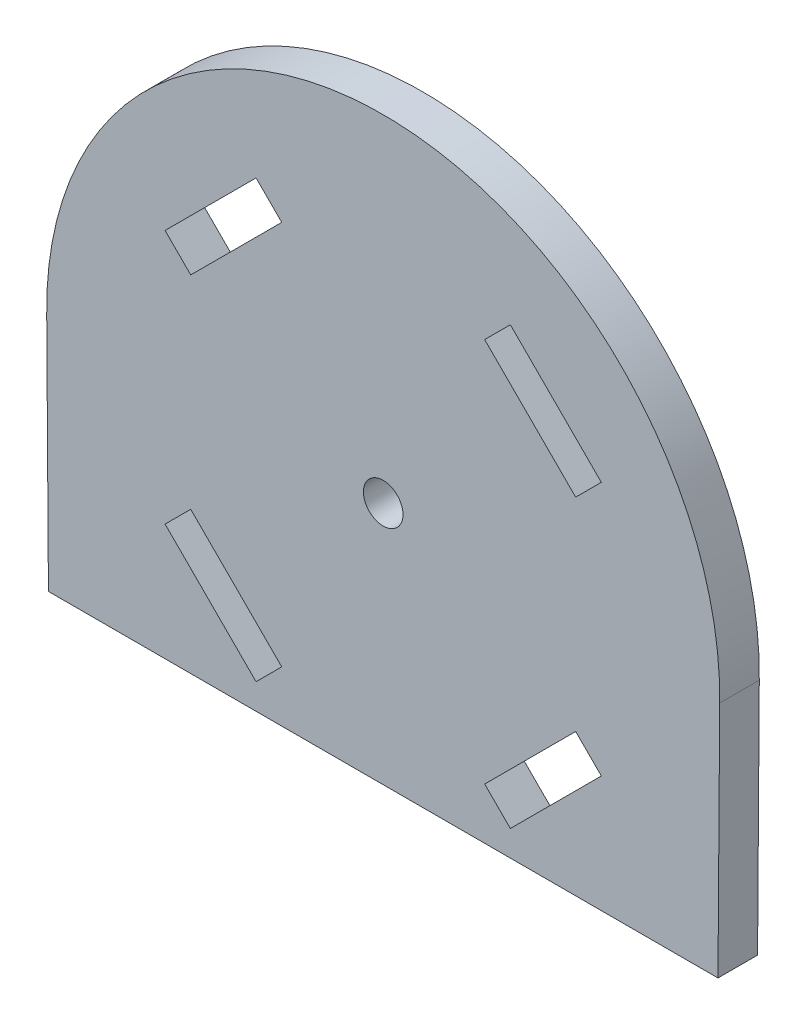
from build123d import *

# Parameters (mm, degrees)
MODEL_R             = 3
BOSS_EXTRUDE1_DEPTH = 6


with BuildPart() as part:
    # Model → Boss-Extrude1 (new body)
    with BuildSketch(Plane.XY):
        with BuildLine():
            Line((122.81162835, 8.788979227), (21.34180525, 8.788979227))
            Line((21.34180525, 8.788979227), (21.081967495, 45.003500256))
            ThreePointArc((21.081967495, 45.003500256), (72.0767168, 96.735308544), (123.071466105, 45.003500256))
            Line((123.071466105, 45.003500256), (122.81162835, 8.788979227))
        make_face()
        with Locations((72.0767168, 45.735308544)):
            Circle(MODEL_R, mode=Mode.SUBTRACT)
        Polygon((49.802853193, 68.009172151), (56.697144309, 74.903463268), (52.808057013, 78.792550564), (39.01947478, 65.003968331), (42.908562076, 61.114881035), align=None, mode=Mode.SUBTRACT)
        Polygon((49.802853193, 23.461444937), (56.697144309, 16.56715382), (52.808057013, 12.678066524), (39.01947478, 26.466648757), (42.908562076, 30.355736053), align=None, mode=Mode.SUBTRACT)
        Polygon((94.350580407, 68.009172151), (101.244871524, 61.114881035), (105.13395882, 65.003968331), (91.345376587, 78.792550564), (87.456289291, 74.903463268), align=None, mode=Mode.SUBTRACT)
        Polygon((94.350580407, 23.461444937), (101.244871524, 30.355736053), (105.13395882, 26.466648757), (91.345376587, 12.678066524), (87.456289291, 16.56715382), align=None, mode=Mode.SUBTRACT)
    extrude(amount=BOSS_EXTRUDE1_DEPTH)


solid = part.part
